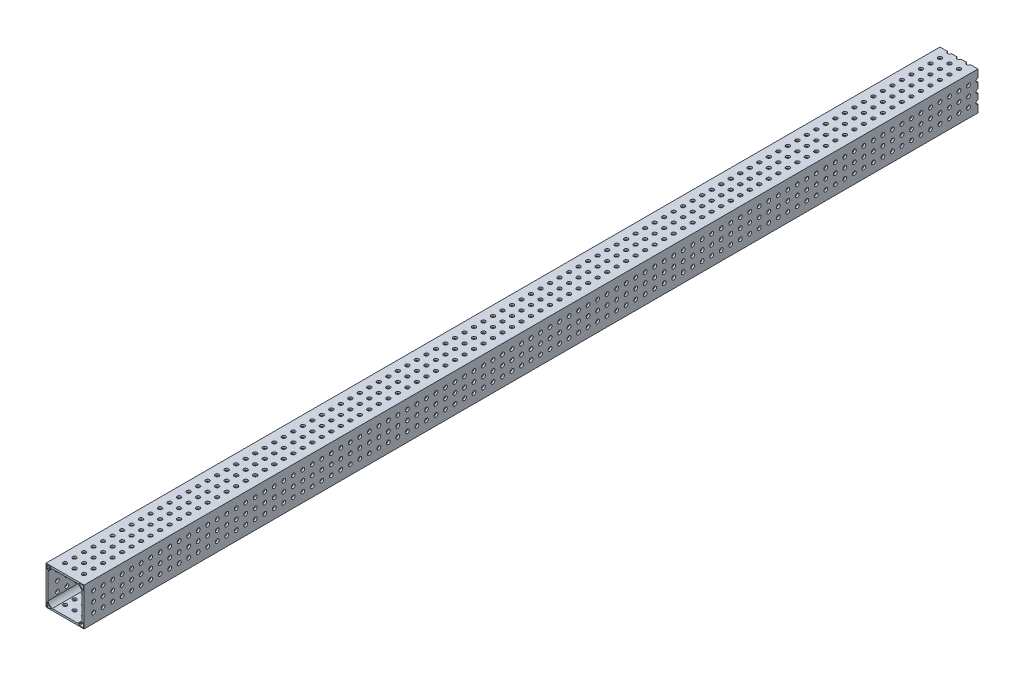
from build123d import *

# Parameters (mm, degrees)
SKETCH1_W                                = 50.8
SKETCH1_H                                = 50.8
BOSS_EXTRUDE1_DEPTH                      = 596.9
CUT_EXTRUDE1_DEPTH                       = 1194.8
MIRROR1_AT_THE_SECOND_PLANE_COPY_1_DEPTH = 1194.8
SKETCH4_R                                = 2.54
CUT_EXTRUDE2_DEPTH                       = 51.8


with BuildPart() as part:
    # Sketch1 → Boss-Extrude1 (new body, symmetric)
    with BuildSketch(Plane.XY):
        Rectangle(SKETCH1_W, SKETCH1_H)
    extrude(amount=BOSS_EXTRUDE1_DEPTH, both=True)

    # Sketch2 → Cut-Extrude1 (cut, through all)
    with BuildSketch(Plane.XY.offset(596.9)):
        with BuildLine():
            Line((0, 0), (0, 22.914082254))
            Line((0, 22.914082254), (-17.077234966, 22.914082254))
            ThreePointArc((-17.077234966, 22.914082254), (-20.557724311, 20.557724311), (-22.914082254, 17.077234966))
            Line((-22.914082254, 17.077234966), (-22.914082254, 0))
            Line((-22.914082254, 0), (0, 0))
        make_face()
        with BuildLine():
            Line((-24.384, 23.692411086), (-24.384, 19.297089168))
            ThreePointArc((-24.384, 19.297089168), (-23.877056001, 18.630604749), (-23.099417578, 18.941204461))
            ThreePointArc((-23.099417578, 18.941204461), (-21.276144801, 21.276144801), (-18.941204461, 23.099417578))
            ThreePointArc((-18.941204461, 23.099417578), (-18.695249844, 23.351699105), (-18.605500254, 23.692411086))
            ThreePointArc((-18.605500254, 23.692411086), (-18.808061957, 24.181438297), (-19.297089168, 24.384))
            Line((-19.297089168, 24.384), (-23.692411086, 24.384))
            ThreePointArc((-23.692411086, 24.384), (-24.181438297, 24.181438297), (-24.384, 23.692411086))
        make_face()
    cut_extrude1 = extrude(amount=-CUT_EXTRUDE1_DEPTH, mode=Mode.SUBTRACT)

    # Mirror1: Cut-Extrude1 across plane
    add(cut_extrude1.mirror(Plane(origin=(0, 0, 0), x_dir=(0, 0, 1), z_dir=(1, 0, 0))), mode=Mode.SUBTRACT)

    # Mirror1 at the second plane: Cut-Extrude1 across plane
    add(cut_extrude1.mirror(Plane.ZX), mode=Mode.SUBTRACT)

    # Mirror1 at the second plane copy 1 sketc → Mirror1 at the second plane copy 1 (cut, through all)
    with BuildSketch(Plane(origin=(0, 0, 596.9), x_dir=(-1, 0, 0), z_dir=(0, 0, 1))):
        with BuildLine():
            Line((0, 0), (0, 22.914082254))
            Line((0, 22.914082254), (-17.077234966, 22.914082254))
            ThreePointArc((-17.077234966, 22.914082254), (-20.557724311, 20.557724311), (-22.914082254, 17.077234966))
            Line((-22.914082254, 17.077234966), (-22.914082254, 0))
            Line((-22.914082254, 0), (0, 0))
        make_face()
        with BuildLine():
            Line((-24.384, 23.692411086), (-24.384, 19.297089168))
            ThreePointArc((-24.384, 19.297089168), (-23.877056001, 18.630604749), (-23.099417578, 18.941204461))
            ThreePointArc((-23.099417578, 18.941204461), (-21.276144801, 21.276144801), (-18.941204461, 23.099417578))
            ThreePointArc((-18.941204461, 23.099417578), (-18.695249844, 23.351699105), (-18.605500254, 23.692411086))
            ThreePointArc((-18.605500254, 23.692411086), (-18.808061957, 24.181438297), (-19.297089168, 24.384))
            Line((-19.297089168, 24.384), (-23.692411086, 24.384))
            ThreePointArc((-23.692411086, 24.384), (-24.181438297, 24.181438297), (-24.384, 23.692411086))
        make_face()
    extrude(amount=-MIRROR1_AT_THE_SECOND_PLANE_COPY_1_DEPTH, mode=Mode.SUBTRACT)

    # Sketch4 → Cut-Extrude2 (cut, through all)
    with BuildSketch(Plane(origin=(0, 25.4, 0), x_dir=(1, 0, 0), z_dir=(0, 1, 0))):
        with Locations((-12.7, -584.2)):
            Circle(SKETCH4_R)
        with Locations((-12.7, -571.5)):
            Circle(SKETCH4_R)
        with Locations((-12.7, -558.8)):
            Circle(SKETCH4_R)
        with Locations((-12.7, -546.1)):
            Circle(SKETCH4_R)
        with Locations((-12.7, -533.4)):
            Circle(SKETCH4_R)
        with Locations((-12.7, -520.7)):
            Circle(SKETCH4_R)
        with Locations((-12.7, -508)):
            Circle(SKETCH4_R)
        with Locations((-12.7, -495.3)):
            Circle(SKETCH4_R)
        with Locations((-12.7, -482.6)):
            Circle(SKETCH4_R)
        with Locations((-12.7, -469.9)):
            Circle(SKETCH4_R)
        with Locations((-12.7, -457.2)):
            Circle(SKETCH4_R)
        with Locations((-12.7, -444.5)):
            Circle(SKETCH4_R)
        with Locations((-12.7, -431.8)):
            Circle(SKETCH4_R)
        with Locations((-12.7, -419.1)):
            Circle(SKETCH4_R)
        with Locations((-12.7, -406.4)):
            Circle(SKETCH4_R)
        with Locations((-12.7, -393.7)):
            Circle(SKETCH4_R)
        with Locations((-12.7, -381)):
            Circle(SKETCH4_R)
        with Locations((-12.7, -368.3)):
            Circle(SKETCH4_R)
        with Locations((-12.7, -355.6)):
            Circle(SKETCH4_R)
        with Locations((-12.7, -342.9)):
            Circle(SKETCH4_R)
        with Locations((-12.7, -330.2)):
            Circle(SKETCH4_R)
        with Locations((-12.7, -317.5)):
            Circle(SKETCH4_R)
        with Locations((-12.7, -304.8)):
            Circle(SKETCH4_R)
        with Locations((-12.7, -292.1)):
            Circle(SKETCH4_R)
        with Locations((-12.7, -279.4)):
            Circle(SKETCH4_R)
        with Locations((-12.7, -266.7)):
            Circle(SKETCH4_R)
        with Locations((-12.7, -254)):
            Circle(SKETCH4_R)
        with Locations((-12.7, -241.3)):
            Circle(SKETCH4_R)
        with Locations((-12.7, -228.6)):
            Circle(SKETCH4_R)
        with Locations((-12.7, -215.9)):
            Circle(SKETCH4_R)
        with Locations((-12.7, -203.2)):
            Circle(SKETCH4_R)
        with Locations((-12.7, -190.5)):
            Circle(SKETCH4_R)
        with Locations((-12.7, -177.8)):
            Circle(SKETCH4_R)
        with Locations((-12.7, -165.1)):
            Circle(SKETCH4_R)
        with Locations((-12.7, -152.4)):
            Circle(SKETCH4_R)
        with Locations((-12.7, -139.7)):
            Circle(SKETCH4_R)
        with Locations((-12.7, -127)):
            Circle(SKETCH4_R)
        with Locations((-12.7, -114.3)):
            Circle(SKETCH4_R)
        with Locations((-12.7, -101.6)):
            Circle(SKETCH4_R)
        with Locations((-12.7, -88.9)):
            Circle(SKETCH4_R)
        with Locations((-12.7, -76.2)):
            Circle(SKETCH4_R)
        with Locations((-12.7, -63.5)):
            Circle(SKETCH4_R)
        with Locations((-12.7, -50.8)):
            Circle(SKETCH4_R)
        with Locations((-12.7, -38.1)):
            Circle(SKETCH4_R)
        with Locations((-12.7, -25.4)):
            Circle(SKETCH4_R)
        with Locations((-12.7, -12.7)):
            Circle(SKETCH4_R)
        with Locations((-12.7, 0)):
            Circle(SKETCH4_R)
        with Locations((-12.7, 12.7)):
            Circle(SKETCH4_R)
        with Locations((-12.7, 25.4)):
            Circle(SKETCH4_R)
        with Locations((-12.7, 38.1)):
            Circle(SKETCH4_R)
        with Locations((-12.7, 50.8)):
            Circle(SKETCH4_R)
        with Locations((-12.7, 63.5)):
            Circle(SKETCH4_R)
        with Locations((-12.7, 76.2)):
            Circle(SKETCH4_R)
        with Locations((-12.7, 88.9)):
            Circle(SKETCH4_R)
        with Locations((-12.7, 101.6)):
            Circle(SKETCH4_R)
        with Locations((-12.7, 114.3)):
            Circle(SKETCH4_R)
        with Locations((-12.7, 127)):
            Circle(SKETCH4_R)
        with Locations((-12.7, 139.7)):
            Circle(SKETCH4_R)
        with Locations((-12.7, 152.4)):
            Circle(SKETCH4_R)
        with Locations((-12.7, 165.1)):
            Circle(SKETCH4_R)
        with Locations((-12.7, 177.8)):
            Circle(SKETCH4_R)
        with Locations((-12.7, 190.5)):
            Circle(SKETCH4_R)
        with Locations((-12.7, 203.2)):
            Circle(SKETCH4_R)
        with Locations((-12.7, 215.9)):
            Circle(SKETCH4_R)
        with Locations((-12.7, 228.6)):
            Circle(SKETCH4_R)
        with Locations((-12.7, 241.3)):
            Circle(SKETCH4_R)
        with Locations((-12.7, 254)):
            Circle(SKETCH4_R)
        with Locations((-12.7, 266.7)):
            Circle(SKETCH4_R)
        with Locations((-12.7, 279.4)):
            Circle(SKETCH4_R)
        with Locations((-12.7, 292.1)):
            Circle(SKETCH4_R)
        with Locations((-12.7, 304.8)):
            Circle(SKETCH4_R)
        with Locations((-12.7, 317.5)):
            Circle(SKETCH4_R)
        with Locations((-12.7, 330.2)):
            Circle(SKETCH4_R)
        with Locations((-12.7, 342.9)):
            Circle(SKETCH4_R)
        with Locations((-12.7, 355.6)):
            Circle(SKETCH4_R)
        with Locations((-12.7, 368.3)):
            Circle(SKETCH4_R)
        with Locations((-12.7, 381)):
            Circle(SKETCH4_R)
        with Locations((-12.7, 393.7)):
            Circle(SKETCH4_R)
        with Locations((-12.7, 406.4)):
            Circle(SKETCH4_R)
        with Locations((-12.7, 419.1)):
            Circle(SKETCH4_R)
        with Locations((-12.7, 431.8)):
            Circle(SKETCH4_R)
        with Locations((-12.7, 444.5)):
            Circle(SKETCH4_R)
        with Locations((-12.7, 457.2)):
            Circle(SKETCH4_R)
        with Locations((-12.7, 469.9)):
            Circle(SKETCH4_R)
        with Locations((-12.7, 482.6)):
            Circle(SKETCH4_R)
        with Locations((-12.7, 495.3)):
            Circle(SKETCH4_R)
        with Locations((-12.7, 508)):
            Circle(SKETCH4_R)
        with Locations((-12.7, 520.7)):
            Circle(SKETCH4_R)
        with Locations((-12.7, 533.4)):
            Circle(SKETCH4_R)
        with Locations((-12.7, 546.1)):
            Circle(SKETCH4_R)
        with Locations((-12.7, 558.8)):
            Circle(SKETCH4_R)
        with Locations((-12.7, 571.5)):
            Circle(SKETCH4_R)
        with Locations((-12.7, 584.2)):
            Circle(SKETCH4_R)
        with Locations((-12.7, 596.9)):
            Circle(SKETCH4_R)
        with Locations((0, -571.5)):
            Circle(SKETCH4_R)
        with Locations((0, -558.8)):
            Circle(SKETCH4_R)
        with Locations((0, -546.1)):
            Circle(SKETCH4_R)
        with Locations((0, -533.4)):
            Circle(SKETCH4_R)
        with Locations((0, -520.7)):
            Circle(SKETCH4_R)
        with Locations((0, -508)):
            Circle(SKETCH4_R)
        with Locations((0, -495.3)):
            Circle(SKETCH4_R)
        with Locations((0, -482.6)):
            Circle(SKETCH4_R)
        with Locations((0, -469.9)):
            Circle(SKETCH4_R)
        with Locations((0, -457.2)):
            Circle(SKETCH4_R)
        with Locations((0, -444.5)):
            Circle(SKETCH4_R)
        with Locations((0, -431.8)):
            Circle(SKETCH4_R)
        with Locations((0, -419.1)):
            Circle(SKETCH4_R)
        with Locations((0, -406.4)):
            Circle(SKETCH4_R)
        with Locations((0, -393.7)):
            Circle(SKETCH4_R)
        with Locations((0, -381)):
            Circle(SKETCH4_R)
        with Locations((0, -368.3)):
            Circle(SKETCH4_R)
        with Locations((0, -355.6)):
            Circle(SKETCH4_R)
        with Locations((0, -342.9)):
            Circle(SKETCH4_R)
        with Locations((0, -330.2)):
            Circle(SKETCH4_R)
        with Locations((0, -317.5)):
            Circle(SKETCH4_R)
        with Locations((0, -304.8)):
            Circle(SKETCH4_R)
        with Locations((0, -292.1)):
            Circle(SKETCH4_R)
        with Locations((0, -279.4)):
            Circle(SKETCH4_R)
        with Locations((0, -266.7)):
            Circle(SKETCH4_R)
        with Locations((0, -254)):
            Circle(SKETCH4_R)
        with Locations((0, -241.3)):
            Circle(SKETCH4_R)
        with Locations((0, -228.6)):
            Circle(SKETCH4_R)
        with Locations((0, -215.9)):
            Circle(SKETCH4_R)
        with Locations((0, -203.2)):
            Circle(SKETCH4_R)
        with Locations((0, -190.5)):
            Circle(SKETCH4_R)
        with Locations((0, -177.8)):
            Circle(SKETCH4_R)
        with Locations((0, -165.1)):
            Circle(SKETCH4_R)
        with Locations((0, -152.4)):
            Circle(SKETCH4_R)
        with Locations((0, -139.7)):
            Circle(SKETCH4_R)
        with Locations((0, -127)):
            Circle(SKETCH4_R)
        with Locations((0, -114.3)):
            Circle(SKETCH4_R)
        with Locations((0, -101.6)):
            Circle(SKETCH4_R)
        with Locations((0, -88.9)):
            Circle(SKETCH4_R)
        with Locations((0, -76.2)):
            Circle(SKETCH4_R)
        with Locations((0, -63.5)):
            Circle(SKETCH4_R)
        with Locations((0, -50.8)):
            Circle(SKETCH4_R)
        with Locations((0, -38.1)):
            Circle(SKETCH4_R)
        with Locations((0, -25.4)):
            Circle(SKETCH4_R)
        with Locations((0, -12.7)):
            Circle(SKETCH4_R)
        Circle(SKETCH4_R)
        with Locations((0, 12.7)):
            Circle(SKETCH4_R)
        with Locations((0, 25.4)):
            Circle(SKETCH4_R)
        with Locations((0, 38.1)):
            Circle(SKETCH4_R)
        with Locations((0, 50.8)):
            Circle(SKETCH4_R)
        with Locations((0, 63.5)):
            Circle(SKETCH4_R)
        with Locations((0, 76.2)):
            Circle(SKETCH4_R)
        with Locations((0, 88.9)):
            Circle(SKETCH4_R)
        with Locations((0, 101.6)):
            Circle(SKETCH4_R)
        with Locations((0, 114.3)):
            Circle(SKETCH4_R)
        with Locations((0, 127)):
            Circle(SKETCH4_R)
        with Locations((0, 139.7)):
            Circle(SKETCH4_R)
        with Locations((0, 152.4)):
            Circle(SKETCH4_R)
        with Locations((0, 165.1)):
            Circle(SKETCH4_R)
        with Locations((0, 177.8)):
            Circle(SKETCH4_R)
        with Locations((0, 190.5)):
            Circle(SKETCH4_R)
        with Locations((0, 203.2)):
            Circle(SKETCH4_R)
        with Locations((0, 215.9)):
            Circle(SKETCH4_R)
        with Locations((0, 228.6)):
            Circle(SKETCH4_R)
        with Locations((0, 241.3)):
            Circle(SKETCH4_R)
        with Locations((0, 254)):
            Circle(SKETCH4_R)
        with Locations((0, 266.7)):
            Circle(SKETCH4_R)
        with Locations((0, 279.4)):
            Circle(SKETCH4_R)
        with Locations((0, 292.1)):
            Circle(SKETCH4_R)
        with Locations((0, 304.8)):
            Circle(SKETCH4_R)
        with Locations((0, 317.5)):
            Circle(SKETCH4_R)
        with Locations((0, 330.2)):
            Circle(SKETCH4_R)
        with Locations((0, 342.9)):
            Circle(SKETCH4_R)
        with Locations((0, 355.6)):
            Circle(SKETCH4_R)
        with Locations((0, 368.3)):
            Circle(SKETCH4_R)
        with Locations((0, 381)):
            Circle(SKETCH4_R)
        with Locations((0, 393.7)):
            Circle(SKETCH4_R)
        with Locations((0, 406.4)):
            Circle(SKETCH4_R)
        with Locations((0, 419.1)):
            Circle(SKETCH4_R)
        with Locations((0, 431.8)):
            Circle(SKETCH4_R)
        with Locations((0, 444.5)):
            Circle(SKETCH4_R)
        with Locations((0, 457.2)):
            Circle(SKETCH4_R)
        with Locations((0, 469.9)):
            Circle(SKETCH4_R)
        with Locations((0, 482.6)):
            Circle(SKETCH4_R)
        with Locations((0, 495.3)):
            Circle(SKETCH4_R)
        with Locations((0, 508)):
            Circle(SKETCH4_R)
        with Locations((0, 520.7)):
            Circle(SKETCH4_R)
        with Locations((0, 533.4)):
            Circle(SKETCH4_R)
        with Locations((0, 546.1)):
            Circle(SKETCH4_R)
        with Locations((0, 558.8)):
            Circle(SKETCH4_R)
        with Locations((0, 571.5)):
            Circle(SKETCH4_R)
        with Locations((0, 584.2)):
            Circle(SKETCH4_R)
        with Locations((0, 596.9)):
            Circle(SKETCH4_R)
        with Locations((12.7, -571.5)):
            Circle(SKETCH4_R)
        with Locations((12.7, -558.8)):
            Circle(SKETCH4_R)
        with Locations((12.7, -546.1)):
            Circle(SKETCH4_R)
        with Locations((12.7, -533.4)):
            Circle(SKETCH4_R)
        with Locations((12.7, -520.7)):
            Circle(SKETCH4_R)
        with Locations((12.7, -508)):
            Circle(SKETCH4_R)
        with Locations((12.7, -495.3)):
            Circle(SKETCH4_R)
        with Locations((12.7, -482.6)):
            Circle(SKETCH4_R)
        with Locations((12.7, -469.9)):
            Circle(SKETCH4_R)
        with Locations((12.7, -457.2)):
            Circle(SKETCH4_R)
        with Locations((12.7, -444.5)):
            Circle(SKETCH4_R)
        with Locations((12.7, -431.8)):
            Circle(SKETCH4_R)
        with Locations((12.7, -419.1)):
            Circle(SKETCH4_R)
        with Locations((12.7, -406.4)):
            Circle(SKETCH4_R)
        with Locations((12.7, -393.7)):
            Circle(SKETCH4_R)
        with Locations((12.7, -381)):
            Circle(SKETCH4_R)
        with Locations((12.7, -368.3)):
            Circle(SKETCH4_R)
        with Locations((12.7, -355.6)):
            Circle(SKETCH4_R)
        with Locations((12.7, -342.9)):
            Circle(SKETCH4_R)
        with Locations((12.7, -330.2)):
            Circle(SKETCH4_R)
        with Locations((12.7, -317.5)):
            Circle(SKETCH4_R)
        with Locations((12.7, -304.8)):
            Circle(SKETCH4_R)
        with Locations((12.7, -292.1)):
            Circle(SKETCH4_R)
        with Locations((12.7, -279.4)):
            Circle(SKETCH4_R)
        with Locations((12.7, -266.7)):
            Circle(SKETCH4_R)
        with Locations((12.7, -254)):
            Circle(SKETCH4_R)
        with Locations((12.7, -241.3)):
            Circle(SKETCH4_R)
        with Locations((12.7, -228.6)):
            Circle(SKETCH4_R)
        with Locations((12.7, -215.9)):
            Circle(SKETCH4_R)
        with Locations((12.7, -203.2)):
            Circle(SKETCH4_R)
        with Locations((12.7, -190.5)):
            Circle(SKETCH4_R)
        with Locations((12.7, -177.8)):
            Circle(SKETCH4_R)
        with Locations((12.7, -165.1)):
            Circle(SKETCH4_R)
        with Locations((12.7, -152.4)):
            Circle(SKETCH4_R)
        with Locations((12.7, -139.7)):
            Circle(SKETCH4_R)
        with Locations((12.7, -127)):
            Circle(SKETCH4_R)
        with Locations((12.7, -114.3)):
            Circle(SKETCH4_R)
        with Locations((12.7, -101.6)):
            Circle(SKETCH4_R)
        with Locations((12.7, -88.9)):
            Circle(SKETCH4_R)
        with Locations((12.7, -76.2)):
            Circle(SKETCH4_R)
        with Locations((12.7, -63.5)):
            Circle(SKETCH4_R)
        with Locations((12.7, -50.8)):
            Circle(SKETCH4_R)
        with Locations((12.7, -38.1)):
            Circle(SKETCH4_R)
        with Locations((12.7, -25.4)):
            Circle(SKETCH4_R)
        with Locations((12.7, -12.7)):
            Circle(SKETCH4_R)
        with Locations((12.7, 0)):
            Circle(SKETCH4_R)
        with Locations((12.7, 12.7)):
            Circle(SKETCH4_R)
        with Locations((12.7, 25.4)):
            Circle(SKETCH4_R)
        with Locations((12.7, 38.1)):
            Circle(SKETCH4_R)
        with Locations((12.7, 50.8)):
            Circle(SKETCH4_R)
        with Locations((12.7, 63.5)):
            Circle(SKETCH4_R)
        with Locations((12.7, 76.2)):
            Circle(SKETCH4_R)
        with Locations((12.7, 88.9)):
            Circle(SKETCH4_R)
        with Locations((12.7, 101.6)):
            Circle(SKETCH4_R)
        with Locations((12.7, 114.3)):
            Circle(SKETCH4_R)
        with Locations((12.7, 127)):
            Circle(SKETCH4_R)
        with Locations((12.7, 139.7)):
            Circle(SKETCH4_R)
        with Locations((12.7, 152.4)):
            Circle(SKETCH4_R)
        with Locations((12.7, 165.1)):
            Circle(SKETCH4_R)
        with Locations((12.7, 177.8)):
            Circle(SKETCH4_R)
        with Locations((12.7, 190.5)):
            Circle(SKETCH4_R)
        with Locations((12.7, 203.2)):
            Circle(SKETCH4_R)
        with Locations((12.7, 215.9)):
            Circle(SKETCH4_R)
        with Locations((12.7, 228.6)):
            Circle(SKETCH4_R)
        with Locations((12.7, 241.3)):
            Circle(SKETCH4_R)
        with Locations((12.7, 254)):
            Circle(SKETCH4_R)
        with Locations((12.7, 266.7)):
            Circle(SKETCH4_R)
        with Locations((12.7, 279.4)):
            Circle(SKETCH4_R)
        with Locations((12.7, 292.1)):
            Circle(SKETCH4_R)
        with Locations((12.7, 304.8)):
            Circle(SKETCH4_R)
        with Locations((12.7, 317.5)):
            Circle(SKETCH4_R)
        with Locations((12.7, 330.2)):
            Circle(SKETCH4_R)
        with Locations((12.7, 342.9)):
            Circle(SKETCH4_R)
        with Locations((12.7, 355.6)):
            Circle(SKETCH4_R)
        with Locations((12.7, 368.3)):
            Circle(SKETCH4_R)
        with Locations((12.7, 381)):
            Circle(SKETCH4_R)
        with Locations((12.7, 393.7)):
            Circle(SKETCH4_R)
        with Locations((12.7, 406.4)):
            Circle(SKETCH4_R)
        with Locations((12.7, 419.1)):
            Circle(SKETCH4_R)
        with Locations((12.7, 431.8)):
            Circle(SKETCH4_R)
        with Locations((12.7, 444.5)):
            Circle(SKETCH4_R)
        with Locations((12.7, 457.2)):
            Circle(SKETCH4_R)
        with Locations((12.7, 469.9)):
            Circle(SKETCH4_R)
        with Locations((12.7, 482.6)):
            Circle(SKETCH4_R)
        with Locations((12.7, 495.3)):
            Circle(SKETCH4_R)
        with Locations((12.7, 508)):
            Circle(SKETCH4_R)
        with Locations((12.7, 520.7)):
            Circle(SKETCH4_R)
        with Locations((12.7, 533.4)):
            Circle(SKETCH4_R)
        with Locations((12.7, 546.1)):
            Circle(SKETCH4_R)
        with Locations((12.7, 558.8)):
            Circle(SKETCH4_R)
        with Locations((12.7, 571.5)):
            Circle(SKETCH4_R)
        with Locations((12.7, 584.2)):
            Circle(SKETCH4_R)
        with Locations((12.7, 596.9)):
            Circle(SKETCH4_R)
        with Locations((0, -584.2)):
            Circle(SKETCH4_R)
        with Locations((12.7, -584.2)):
            Circle(SKETCH4_R)
    cut_extrude2 = extrude(amount=-CUT_EXTRUDE2_DEPTH, mode=Mode.SUBTRACT)

    # Mirror2: Cut-Extrude2 across plane
    add(cut_extrude2.mirror(Plane(origin=(0, 0, 0), x_dir=(0, 0, 1), z_dir=(-0.707106781, 0.707106781, 0))), mode=Mode.SUBTRACT)


solid = part.part
